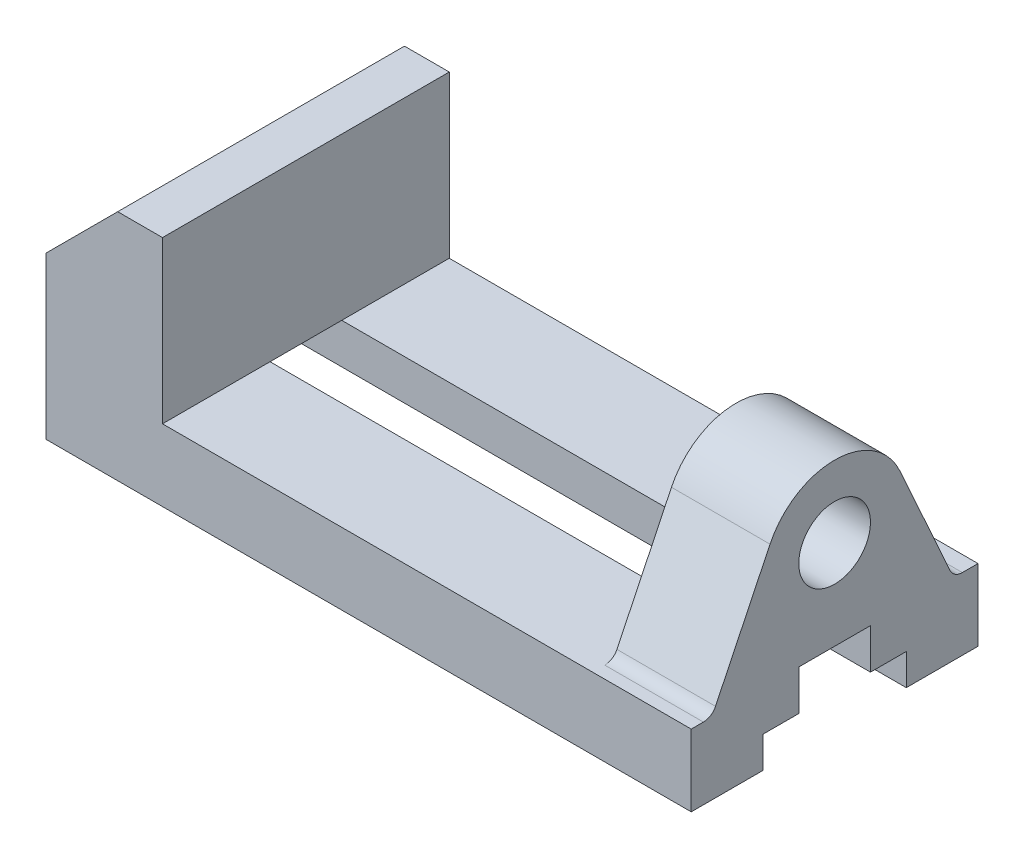
from build123d import *

# Parameters (mm, degrees)
SKETCH1_W                        = 144
SKETCH1_H                        = 64
BOSS_EXTRUDE1_DEPTH              = 16
SKETCH3_W                        = 26
SKETCH3_H                        = 64
BOSS_EXTRUDE2_DEPTH              = 36
CHAMFER1_SIZE                    = 16
CUT_EXTRUDE1_REACH               = 146
SKETCH5_R                        = 8
BOSS_EXTRUDE3_DEPTH              = 22
FILLET1_R                        = 3
TAP_DRILL_FOR_M6_HELICOIL2_D     = 6.25
TAP_DRILL_FOR_M6_HELICOIL2_DEPTH = 10
TAP_DRILL_FOR_M6_HELICOIL2_TIP   = 1.877689434


with BuildPart() as part:
    # Sketch1 → Boss-Extrude1 (new body)
    with BuildSketch(Plane(origin=(0, 0, 0), x_dir=(1, 0, 0), z_dir=(0, 1, 0))):
        Rectangle(SKETCH1_W, SKETCH1_H)
    extrude(amount=BOSS_EXTRUDE1_DEPTH)

    # Sketch3 → Boss-Extrude2 (add)
    with BuildSketch(Plane(origin=(0, 16, 0), x_dir=(1, 0, 0), z_dir=(0, 1, 0))):
        with Locations((-59, 0)):
            Rectangle(SKETCH3_W, SKETCH3_H)
    extrude(amount=BOSS_EXTRUDE2_DEPTH)

    # Chamfer1
    chamfer1_edges = [part.edges().sort_by_distance(p)[0] for p in [
        (-72, 52, 0),
    ]]
    chamfer(chamfer1_edges, length=CHAMFER1_SIZE)

    # Sketch2 → Cut-Extrude1 (cut, up to next)
    with BuildSketch(Plane(origin=(72, 0, 0), x_dir=(0, 0, -1), z_dir=(1, 0, 0)), mode=Mode.PRIVATE) as cut_extrude1_sk1:
        Polygon((-16, 0), (-16, 7), (-8, 7), (-8, 16), (8, 16), (8, 7), (16, 7), (16, 0), align=None)
    cut_extrude1_tool1 = extrude(cut_extrude1_sk1.sketch, amount=-CUT_EXTRUDE1_REACH, mode=Mode.PRIVATE) & part.part
    add(cut_extrude1_tool1.solids().sort_by_distance((72, 6.630435, 0))[0], mode=Mode.SUBTRACT)

    # Sketch5 → Boss-Extrude3 (add)
    with BuildSketch(Plane(origin=(72, 0, 0), x_dir=(0, 0, -1), z_dir=(1, 0, 0))):
        with BuildLine():
            Line((-14.413228488, 42.946858611), (-27.401020705, 16))
            Line((-27.401020705, 16), (26.567243493, 16))
            Line((26.567243493, 16), (14.586247124, 42.575818949))
            ThreePointArc((14.586247124, 42.575818949), (0.204698485, 51.998690525), (-14.413228488, 42.946858611))
        make_face()
        with Locations((0, 36)):
            Circle(SKETCH5_R, mode=Mode.SUBTRACT)
    extrude(amount=-BOSS_EXTRUDE3_DEPTH)

    # Fillet1
    fillet1_edges = [part.edges().sort_by_distance(p)[0] for p in [
        (61, 16, -26.567243493),
        (61, 16, 27.401020705),
    ]]
    fillet(fillet1_edges, radius=FILLET1_R)

    # Tap Drill for M6 Helicoil2
    with Locations(Plane(origin=(-36, 0, 22), x_dir=(0, 0, -1), z_dir=(0, -1, 0))):
        with Locations((0, 0), (0, 70), (44, 0), (44, 70)):
            Hole(TAP_DRILL_FOR_M6_HELICOIL2_D / 2, depth=TAP_DRILL_FOR_M6_HELICOIL2_DEPTH)
            with Locations((0, 0, -(TAP_DRILL_FOR_M6_HELICOIL2_DEPTH + TAP_DRILL_FOR_M6_HELICOIL2_TIP / 2))):  # 118° drill point
                Cone(0, TAP_DRILL_FOR_M6_HELICOIL2_D / 2, TAP_DRILL_FOR_M6_HELICOIL2_TIP, mode=Mode.SUBTRACT)


solid = part.part
